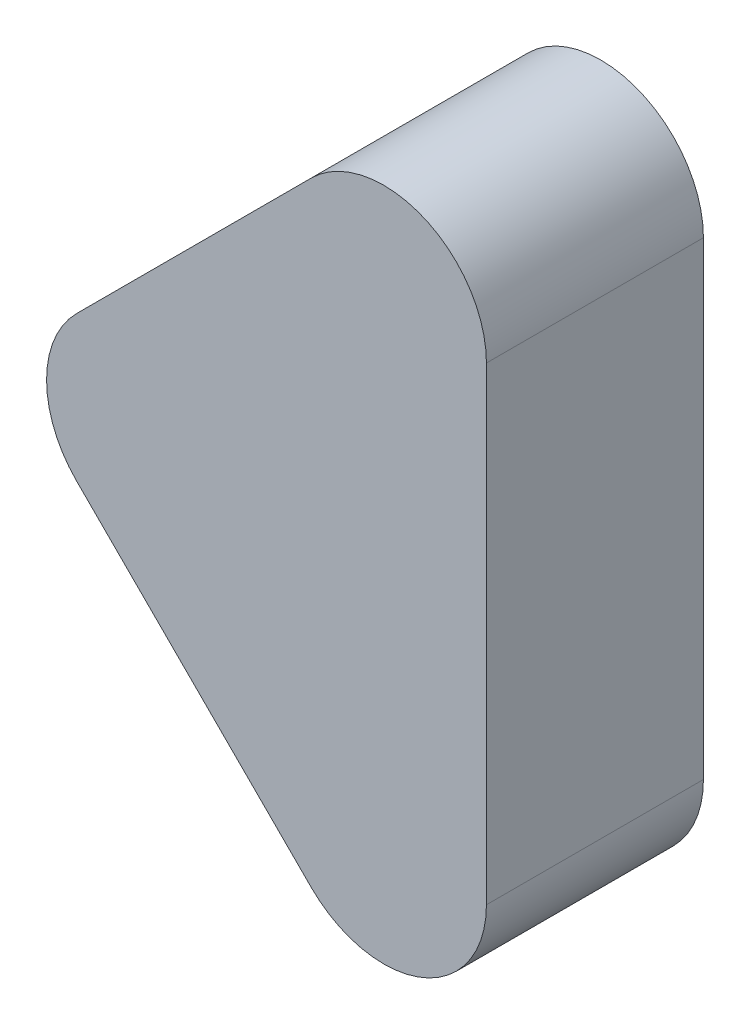
from build123d import *

# Parameters (mm, degrees)
BOSS_EXTRUDE1_DEPTH = 3.7


with BuildPart() as part:
    # Sketch1 → Boss-Extrude1 (new body)
    with BuildSketch(Plane.XY):
        with BuildLine():
            Line((9.75, -19.725), (9.75, -11.725))
            ThreePointArc((9.75, -11.725), (8.669696007, -10.108210818), (6.762563133, -10.487563133))
            Line((6.762563133, -10.487563133), (2.762563133, -14.487563133))
            ThreePointArc((2.762563133, -14.487563133), (2.25, -15.725), (2.762563133, -16.962436867))
            Line((2.762563133, -16.962436867), (6.762563133, -20.962436867))
            ThreePointArc((6.762563133, -20.962436867), (8.669696007, -21.341789182), (9.75, -19.725))
        make_face()
    extrude(amount=BOSS_EXTRUDE1_DEPTH)


solid = part.part
